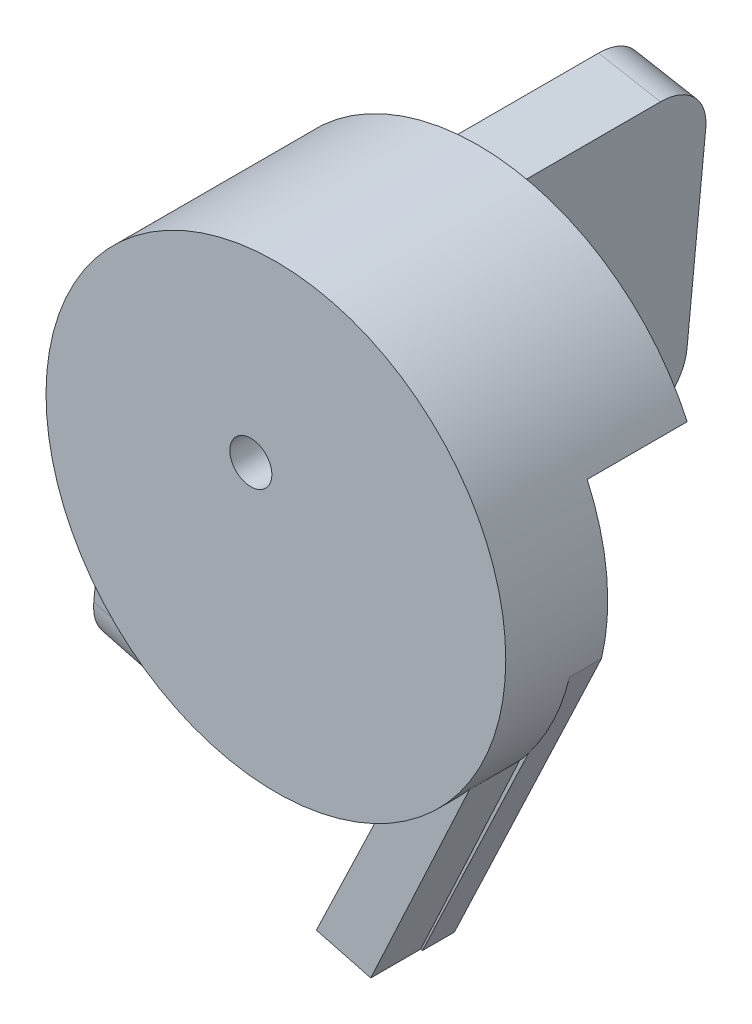
from build123d import *

# Parameters (mm, degrees)
BOSS_EXTRUDE3_DEPTH = 13.2
BOSS_EXTRUDE4_DEPTH = 40
SKETCH3_R           = 23
BOSS_EXTRUDE5_DEPTH = 7
SKETCH4_R           = 2.101716342
CUT_EXTRUDE1_DEPTH  = 10
SKETCH6_W           = 25.714942096
SKETCH6_H           = 53.927163671
CUT_EXTRUDE2_DEPTH  = 10
BOSS_EXTRUDE6_DEPTH = 5
SKETCH11_W          = 0.356169872
SKETCH11_H          = 3.96875
SKETCH11_W_2        = 1.526442308
SKETCH11_H_2        = 0.407051282
CUT_EXTRUDE5_DEPTH  = 5
FILLET5_R           = 5
FILLET6_R           = 5
FILLET7_R           = 5
SKETCH12_R          = 1.4
CUT_EXTRUDE6_DEPTH  = 4
SKETCH13_R          = 1.4
CUT_EXTRUDE7_DEPTH  = 4


with BuildPart() as part:
    # Sketch1 → Boss-Extrude3 (new body)
    with BuildSketch(Plane.XY):
        with BuildLine():
            ThreePointArc((-16.733879942, 0.734685024), (4.365374373, 16.171147349), (14.830379862, -7.786034495))
            Line((14.830379862, -7.786034495), (1.98558973, -34.897127547))
            Line((1.98558973, -34.897127547), (7.660402975, -36.381590217))
            Line((7.660402975, -36.381590217), (22.375667903, -5.322545058))
            ThreePointArc((22.375667903, -5.322545058), (3.672252171, 22.704945805), (-22.912677541, 2.002300652))
            Line((-22.912677541, 2.002300652), (-25.690659105, -27.657354808))
            Line((-25.690659105, -27.657354808), (-19.543738844, -29.265314976))
            Line((-19.543738844, -29.265314976), (-16.733879942, 0.734685024))
        make_face()
    extrude(amount=BOSS_EXTRUDE3_DEPTH)

    # Sketch2 → Boss-Extrude4 (add)
    with BuildSketch(Plane(origin=(0, 0, 0), x_dir=(-1, 0, 0), z_dir=(0, 0, -1))):
        Polygon((22.912677541, 2.002300652), (16.720636216, 0.876084213), (19.543738844, -29.265314976), (25.690659105, -27.657354808), align=None)
    extrude(amount=BOSS_EXTRUDE4_DEPTH)

    # Sketch3 → Boss-Extrude5 (add)
    with BuildSketch(Plane.XY.offset(13.2)):
        Circle(SKETCH3_R)
    extrude(amount=BOSS_EXTRUDE5_DEPTH)

    # Sketch4 → Cut-Extrude1 (cut)
    with BuildSketch(Plane.XY.offset(20.2)):
        with Locations((-2.506003926, 4.326655096)):
            Circle(SKETCH4_R)
    extrude(amount=-CUT_EXTRUDE1_DEPTH, mode=Mode.SUBTRACT)

    # Sketch6 → Cut-Extrude2 (cut)
    with BuildSketch(Plane(origin=(0, 0, 0), x_dir=(-1, 0, 0), z_dir=(0, 0, -1))):
        with Locations((-13.331770184, -17.473361846)):
            Rectangle(SKETCH6_W, SKETCH6_H)
    extrude(amount=-CUT_EXTRUDE2_DEPTH, mode=Mode.SUBTRACT)

    # Sketch7 → Boss-Extrude6 (add)
    with BuildSketch(Plane.XY.offset(13.2)):
        with BuildLine():
            Line((8.554145329, -21.350095964), (2.050563603, -34.914123928))
            Line((2.050563603, -34.914123928), (7.494260499, -36.33812935))
            Line((7.494260499, -36.33812935), (17.377955101, -15.066740739))
            ThreePointArc((17.377955101, -15.066740739), (13.34123669, -18.735298332), (8.554145329, -21.350095964))
        make_face()
    extrude(amount=BOSS_EXTRUDE6_DEPTH)

    # Sketch11 → Cut-Extrude5 (cut)
    with BuildSketch(Plane(origin=(-22.899331118, 2.144796313, 0), x_dir=(0, 0, 1), z_dir=(-0.995642368, 0.093253819, 0))):
        with BuildLine():
            Line((-27.490761449, -14.449425234), (-27.796049911, -14.738813255))
            add(Edge.make_bspline(
                [(-27.796049911, -14.738813255), (-27.85129365, -14.68684433), (-27.96046381, -14.584145708), (-28.138445513, -14.450896634), (-28.324141777, -14.336748466), (-28.516583626, -14.243872645), (-28.711005379, -14.169767282), (-28.904826402, -14.117007695), (-29.096058582, -14.083361157), (-29.223248195, -14.079337559), (-29.285921205, -14.077354922)],
                knots=[0, 0, 0, 0, 0.000227393, 0.000449364, 0.000665615, 0.000880379, 0.001089464, 0.001288886, 0.001482323, 0.001670233, 0.001670233, 0.001670233, 0.001670233], degree=3))
            add(Edge.make_bspline(
                [(-29.285921205, -14.077354922), (-29.324378052, -14.077823921), (-29.401192007, -14.078760704), (-29.515290104, -14.090717091), (-29.628191559, -14.107912963), (-29.739683243, -14.132793485), (-29.849981933, -14.164326972), (-29.958704016, -14.203771203), (-30.066052303, -14.249757953), (-30.171015627, -14.302896651), (-30.272774948, -14.36127112), (-30.368883145, -14.42596009), (-30.459952803, -14.494890236), (-30.544272214, -14.569787329), (-30.622326399, -14.649972935), (-30.695973213, -14.733955434), (-30.762622468, -14.824029298), (-30.822824057, -14.918537284), (-30.87652875, -15.015819499), (-30.923936776, -15.114939585), (-30.963734367, -15.215568777), (-30.995222946, -15.317833348), (-31.021201991, -15.420942141), (-31.039478206, -15.525609101), (-31.0497819, -15.631946298), (-31.051564187, -15.703153904), (-31.052460167, -15.738950975)],
                knots=[0, 0, 0, 0, 0.000115322, 0.000230345, 0.000343799, 0.000457798, 0.000572791, 0.000687718, 0.000804532, 0.000922929, 0.001040474, 0.001156236, 0.001270247, 0.001382882, 0.001494196, 0.001605783, 0.001717723, 0.001829979, 0.001941716, 0.002050889, 0.0021594, 0.002266016, 0.002371682, 0.002478206, 0.002584448, 0.002691849, 0.002691849, 0.002691849, 0.002691849], degree=3))
            add(Edge.make_bspline(
                [(-31.052460167, -15.738950975), (-31.051603236, -15.775543777), (-31.049891715, -15.848629457), (-31.038937603, -15.957706665), (-31.018608259, -16.065163862), (-30.991430589, -16.171354156), (-30.957434486, -16.27645941), (-30.915056552, -16.380023953), (-30.864862523, -16.48204395), (-30.806763932, -16.581600176), (-30.743052791, -16.678577176), (-30.671679833, -16.769925919), (-30.595864707, -16.856862836), (-30.512845374, -16.937457676), (-30.425283929, -17.013866201), (-30.330564295, -17.083983266), (-30.230549005, -17.149159466), (-30.12508547, -17.208573376), (-30.015318029, -17.261650912), (-29.902767961, -17.308849437), (-29.787075706, -17.347719757), (-29.668849263, -17.379399571), (-29.548229571, -17.405366873), (-29.424604366, -17.422072453), (-29.298882634, -17.434195092), (-29.214134364, -17.43508145), (-29.171438032, -17.435527998)],
                knots=[0, 0, 0, 0, 0.000109785, 0.00021927, 0.000328423, 0.000437561, 0.000547932, 0.000659544, 0.000772965, 0.000888736, 0.00100516, 0.001120769, 0.001236245, 0.001350932, 0.001467605, 0.001584633, 0.001704151, 0.001825542, 0.001947502, 0.002069752, 0.002191435, 0.00231332, 0.002436812, 0.002561276, 0.002687381, 0.002815419, 0.002815419, 0.002815419, 0.002815419], degree=3))
            add(Edge.make_bspline(
                [(-29.171438032, -17.435527998), (-29.119982227, -17.434452381), (-29.018940395, -17.43234023), (-28.870411125, -17.415897938), (-28.727759429, -17.390218092), (-28.591386145, -17.352610334), (-28.461132881, -17.304640988), (-28.336522135, -17.246815862), (-28.218534986, -17.176917036), (-28.106816744, -17.098025241), (-28.003904579, -17.010128957), (-27.911087849, -16.91528212), (-27.829846982, -16.813945116), (-27.758971117, -16.706714803), (-27.700337197, -16.592703609), (-27.652210099, -16.472470257), (-27.61531967, -16.345960667), (-27.600176082, -16.258544263), (-27.59252427, -16.214374152)],
                knots=[0, 0, 0, 0, 0.000154335, 0.000303061, 0.000447768, 0.000588759, 0.000726848, 0.000863779, 0.001000266, 0.001137694, 0.001273596, 0.001405716, 0.001535217, 0.001662669, 0.001790677, 0.001919117, 0.002050709, 0.002185113, 0.002185113, 0.002185113, 0.002185113], degree=3))
            Line((-27.59252427, -16.214374152), (-28.915440936, -16.214374152))
            Line((-28.915440936, -16.214374152), (-28.915440936, -15.80732287))
            Line((-28.915440936, -15.80732287), (-27.236354398, -15.80732287))
            add(Edge.make_bspline(
                [(-27.236354398, -15.80732287), (-27.238288708, -15.883191183), (-27.242074503, -16.031679177), (-27.26862988, -16.248225824), (-27.311511104, -16.45275444), (-27.370090207, -16.645480423), (-27.445921999, -16.826130658), (-27.538192633, -16.99488856), (-27.648378878, -17.150663903), (-27.772555896, -17.294728398), (-27.91191567, -17.42323563), (-28.062692587, -17.536181649), (-28.225135757, -17.631321222), (-28.399091521, -17.708723937), (-28.583990405, -17.769132842), (-28.780260264, -17.811963112), (-28.987634936, -17.837623874), (-29.129757775, -17.840902492), (-29.202443891, -17.84257928)],
                knots=[0, 0, 0, 0, 0.000227576, 0.000445408, 0.000653412, 0.000853841, 0.001048745, 0.001240174, 0.001429639, 0.00162013, 0.00180972, 0.001997187, 0.002184263, 0.002373234, 0.002567323, 0.002766779, 0.002975044, 0.003193056, 0.003193056, 0.003193056, 0.003193056], degree=3))
            add(Edge.make_bspline(
                [(-29.202443891, -17.84257928), (-29.247245562, -17.841933938), (-29.335608898, -17.840661114), (-29.466113789, -17.831615371), (-29.593020377, -17.817690075), (-29.716310173, -17.79666123), (-29.836436686, -17.770904434), (-29.952799965, -17.737922173), (-30.06584328, -17.699744273), (-30.175741353, -17.656319714), (-30.281496687, -17.606005425), (-30.383580327, -17.550091816), (-30.482556559, -17.488867202), (-30.577751183, -17.421272761), (-30.6696602, -17.347814078), (-30.75769098, -17.26834392), (-30.842336342, -17.18310524), (-30.895359368, -17.122577255), (-30.922076553, -17.092078479)],
                knots=[0, 0, 0, 0, 0.000134396, 0.000265073, 0.000392289, 0.000517239, 0.000640121, 0.000760684, 0.000879852, 0.000997958, 0.001114959, 0.001230945, 0.001346988, 0.001463899, 0.001580984, 0.001699762, 0.001819504, 0.001941119, 0.001941119, 0.001941119, 0.001941119], degree=3))
            add(Edge.make_bspline(
                [(-30.922076553, -17.092078479), (-30.960840958, -17.043693007), (-31.037726319, -16.94772521), (-31.136693514, -16.793964559), (-31.221059391, -16.634758878), (-31.289512189, -16.469664969), (-31.342963412, -16.298837255), (-31.381297288, -16.122494023), (-31.403757339, -15.940408192), (-31.406993047, -15.817189543), (-31.408630039, -15.754851416)],
                knots=[0, 0, 0, 0, 0.000185896, 0.000368706, 0.000547588, 0.000725795, 0.000904073, 0.00108387, 0.001266496, 0.001453496, 0.001453496, 0.001453496, 0.001453496], degree=3))
            add(Edge.make_bspline(
                [(-31.408630039, -15.754851416), (-31.408026519, -15.708171826), (-31.406827149, -15.615405915), (-31.39228393, -15.477682004), (-31.371418036, -15.34240354), (-31.340748608, -15.209681106), (-31.30208588, -15.07942606), (-31.253833266, -14.951577922), (-31.197652893, -14.826061246), (-31.132355053, -14.703739985), (-31.059687854, -14.586237303), (-30.980822872, -14.474026222), (-30.894640218, -14.369150229), (-30.802547303, -14.270281128), (-30.703445358, -14.178661007), (-30.598262797, -14.093441613), (-30.48691856, -14.014508635), (-30.369062356, -13.94310534), (-30.246453286, -13.878966235), (-30.119385248, -13.822735611), (-29.987897033, -13.776263458), (-29.852973733, -13.736832476), (-29.713594067, -13.707673343), (-29.570769485, -13.686526998), (-29.423755518, -13.67205739), (-29.324382521, -13.670893689), (-29.273995874, -13.670303639)],
                knots=[0, 0, 0, 0, 0.00013998, 0.000278182, 0.000415029, 0.000550417, 0.000686496, 0.000822349, 0.000960062, 0.00109877, 0.00123799, 0.00137431, 0.001509903, 0.001644898, 0.00177935, 0.001914441, 0.002050761, 0.002188472, 0.002327512, 0.002465629, 0.002604942, 0.002745598, 0.002887025, 0.003031729, 0.003178637, 0.003329743, 0.003329743, 0.003329743, 0.003329743], degree=3))
            add(Edge.make_bspline(
                [(-29.273995874, -13.670303639), (-29.232904294, -13.670960742), (-29.15142452, -13.672263698), (-29.030178377, -13.68129504), (-28.910806298, -13.69560962), (-28.793131285, -13.715143565), (-28.677554066, -13.741749714), (-28.563745391, -13.773588483), (-28.451540283, -13.810658675), (-28.341290393, -13.854869242), (-28.232254412, -13.905049692), (-28.123826075, -13.961534555), (-28.016375858, -14.025289694), (-27.909717424, -14.096504417), (-27.803178192, -14.173955614), (-27.698443285, -14.259858441), (-27.59298459, -14.350825316), (-27.525173604, -14.416232792), (-27.490761449, -14.449425234)],
                knots=[0, 0, 0, 0, 0.000123269, 0.000244429, 0.000364538, 0.000483868, 0.000602094, 0.000720146, 0.000838308, 0.000956413, 0.001076296, 0.001198266, 0.001323024, 0.001450914, 0.001582897, 0.001717987, 0.001857171, 0.002000577, 0.002000577, 0.002000577, 0.002000577], degree=3))
        make_face()
        with Locations((-26.244166898, -15.75644146)):
            Rectangle(SKETCH11_W, SKETCH11_H)
        Polygon((-23.420248629, -13.77206646), (-21.588517859, -17.74081646), (-21.975693591, -17.74081646), (-22.562419853, -16.468781204), (-24.361554718, -16.468781204), (-24.964976443, -17.74081646), (-25.353742218, -17.74081646), (-23.471130039, -13.77206646), align=None)
        Polygon((-23.449664444, -14.5456229), (-24.168364364, -16.061729922), (-22.750045053, -16.061729922), align=None, mode=Mode.SUBTRACT)
        with BuildLine():
            Line((-20.876178116, -13.77206646), (-20.520008244, -13.77206646))
            Line((-20.520008244, -13.77206646), (-20.520008244, -16.149977367))
            add(Edge.make_bspline(
                [(-20.520008244, -16.149977367), (-20.520061248, -16.183633202), (-20.520161833, -16.247500947), (-20.519489965, -16.338406074), (-20.517608359, -16.419223951), (-20.516422089, -16.490266104), (-20.513783059, -16.551206541), (-20.51163081, -16.60237542), (-20.508863393, -16.643530453), (-20.505537447, -16.667548111), (-20.504107803, -16.677871999)],
                knots=[0, 0, 0, 0, 0.000100968, 0.000191604, 0.000272712, 0.000343486, 0.00040475, 0.000455687, 0.00049715, 0.00052841, 0.00052841, 0.00052841, 0.00052841], degree=3))
            add(Edge.make_bspline(
                [(-20.504107803, -16.677871999), (-20.498236935, -16.715117882), (-20.486826, -16.787510977), (-20.45774484, -16.890594475), (-20.417130352, -16.983498897), (-20.369002973, -17.069123307), (-20.305579387, -17.145084456), (-20.229602164, -17.215061063), (-20.137552373, -17.276261234), (-20.035203293, -17.332221529), (-19.924888783, -17.3771989), (-19.812163508, -17.411209232), (-19.698721915, -17.431936199), (-19.622775728, -17.434336203), (-19.58506233, -17.435527998)],
                knots=[0, 0, 0, 0, 0.000113064, 0.000219757, 0.000320182, 0.000416724, 0.000513328, 0.000615741, 0.000725557, 0.000844018, 0.00096523, 0.001082195, 0.001196825, 0.001309897, 0.001309897, 0.001309897, 0.001309897], degree=3))
            add(Edge.make_bspline(
                [(-19.58506233, -17.435527998), (-19.552684428, -17.434310329), (-19.488115631, -17.431882023), (-19.392177981, -17.416844507), (-19.298742144, -17.389742973), (-19.20734673, -17.35477289), (-19.12167731, -17.308568032), (-19.041686086, -17.255193062), (-18.970289482, -17.192587872), (-18.905136217, -17.123304446), (-18.848400173, -17.045131637), (-18.799220397, -16.959771606), (-18.75893653, -16.865939757), (-18.739043426, -16.799996796), (-18.728823599, -16.766119445)],
                knots=[0, 0, 0, 0, 9.7152e-05, 0.000193743, 0.00029039, 0.000388568, 0.00048673, 0.000581767, 0.000676452, 0.000770956, 0.000866524, 0.000965529, 0.001065954, 0.001172053, 0.001172053, 0.001172053, 0.001172053], degree=3))
            add(Edge.make_bspline(
                [(-18.728823599, -16.766119445), (-18.725421671, -16.752117043), (-18.717840805, -16.720914051), (-18.710757102, -16.66816223), (-18.703379167, -16.605921612), (-18.698259967, -16.533745003), (-18.693269297, -16.451874257), (-18.690283581, -16.359882876), (-18.688903552, -16.258104893), (-18.688492299, -16.187078826), (-18.688277475, -16.149977367)],
                knots=[0, 0, 0, 0, 4.3203e-05, 9.6273e-05, 0.000159486, 0.000231254, 0.00031328, 0.000405558, 0.000507333, 0.000618639, 0.000618639, 0.000618639, 0.000618639], degree=3))
            Line((-18.688277475, -16.149977367), (-18.688277475, -13.77206646))
            Line((-18.688277475, -13.77206646), (-18.332107603, -13.77206646))
            Line((-18.332107603, -13.77206646), (-18.332107603, -16.169057896))
            add(Edge.make_bspline(
                [(-18.332107603, -16.169057896), (-18.332395757, -16.212258737), (-18.332958108, -16.296567803), (-18.337834655, -16.420110862), (-18.345610003, -16.537305761), (-18.356595602, -16.648168252), (-18.371151847, -16.752301629), (-18.387338927, -16.850618643), (-18.407953219, -16.942413555), (-18.43203038, -17.0284021), (-18.459554849, -17.110255316), (-18.495206866, -17.187939191), (-18.535375718, -17.263815341), (-18.583017334, -17.336736143), (-18.636551669, -17.407024466), (-18.697162057, -17.474254043), (-18.762843918, -17.539499211), (-18.834689133, -17.601086349), (-18.91151339, -17.65756583), (-18.993088163, -17.707229374), (-19.078786822, -17.749211512), (-19.168386599, -17.783769034), (-19.26192573, -17.809752552), (-19.359406576, -17.829114559), (-19.461051018, -17.840116272), (-19.530180584, -17.841751317), (-19.56518678, -17.84257928)],
                knots=[0, 0, 0, 0, 0.000129598, 0.000252919, 0.000370851, 0.000481918, 0.000587044, 0.000686247, 0.000780758, 0.000869105, 0.000954087, 0.001039492, 0.001125214, 0.001211437, 0.001300483, 0.00139001, 0.001482769, 0.001578056, 0.001673624, 0.001768522, 0.001864166, 0.001959545, 0.002056192, 0.002155044, 0.002257413, 0.002362431, 0.002362431, 0.002362431, 0.002362431], degree=3))
            add(Edge.make_bspline(
                [(-19.56518678, -17.84257928), (-19.603365137, -17.841689413), (-19.678270938, -17.839943495), (-19.788645353, -17.829939127), (-19.894456987, -17.811095055), (-19.996823383, -17.78710119), (-20.094350875, -17.754008917), (-20.18834612, -17.715344079), (-20.277199267, -17.667858257), (-20.362351779, -17.615024677), (-20.441528065, -17.555578882), (-20.514209942, -17.490786006), (-20.580517403, -17.421683971), (-20.639332799, -17.347524628), (-20.691630588, -17.268884746), (-20.736681812, -17.185541858), (-20.775363794, -17.097528231), (-20.795328384, -17.036349156), (-20.805421155, -17.005421077)],
                knots=[0, 0, 0, 0, 0.000114552, 0.000224751, 0.000332058, 0.000436763, 0.00053984, 0.000640686, 0.000741328, 0.000841696, 0.000941074, 0.001037929, 0.001133524, 0.001228011, 0.001321503, 0.001416488, 0.001511904, 0.001609455, 0.001609455, 0.001609455, 0.001609455], degree=3))
            add(Edge.make_bspline(
                [(-20.805421155, -17.005421077), (-20.811291682, -16.984293069), (-20.824024987, -16.938465948), (-20.837660816, -16.862621447), (-20.849123792, -16.775292032), (-20.859902416, -16.676471724), (-20.866262574, -16.566083928), (-20.871838598, -16.444176497), (-20.876217398, -16.310602023), (-20.876191576, -16.217558063), (-20.876178116, -16.169057896)],
                knots=[0, 0, 0, 0, 6.5757e-05, 0.000142627, 0.000230889, 0.000330012, 0.000440752, 0.000562517, 0.00069614, 0.000841631, 0.000841631, 0.000841631, 0.000841631], degree=3))
            Line((-20.876178116, -16.169057896), (-20.876178116, -13.77206646))
        make_face()
        with Locations((-16.907428116, -16.214374152)):
            Rectangle(SKETCH11_W_2, SKETCH11_H_2)
        with BuildLine():
            Line((-12.17466194, -17.298784208), (-11.564880039, -18.046104922))
            Line((-11.564880039, -18.046104922), (-12.009297357, -18.046104922))
            Line((-12.009297357, -18.046104922), (-12.449739564, -17.507079982))
            add(Edge.make_bspline(
                [(-12.449739564, -17.507079982), (-12.493914125, -17.533924307), (-12.581449515, -17.587118463), (-12.717936684, -17.655682777), (-12.857138096, -17.71273723), (-12.998745753, -17.759874611), (-13.142553396, -17.79760532), (-13.28929026, -17.823792027), (-13.438424142, -17.838998322), (-13.538620794, -17.841381077), (-13.589006141, -17.84257928)],
                knots=[0, 0, 0, 0, 0.000155029, 0.000307203, 0.000457647, 0.000605978, 0.000754649, 0.000903267, 0.001052702, 0.001203858, 0.001203858, 0.001203858, 0.001203858], degree=3))
            add(Edge.make_bspline(
                [(-13.589006141, -17.84257928), (-13.66119242, -17.840840575), (-13.803233529, -17.837419321), (-14.011842501, -17.807551124), (-14.212075712, -17.761422321), (-14.403534053, -17.694678532), (-14.586426086, -17.609426967), (-14.760666841, -17.504323949), (-14.926344878, -17.380825276), (-15.081014538, -17.239738051), (-15.222444253, -17.086254803), (-15.346539965, -16.922264875), (-15.452054849, -16.750489484), (-15.537369919, -16.570072038), (-15.605078829, -16.3825832), (-15.651220615, -16.186463683), (-15.681087656, -15.982880958), (-15.684528412, -15.844265934), (-15.68627427, -15.773931945)],
                knots=[0, 0, 0, 0, 0.000216456, 0.000425922, 0.000630911, 0.000832053, 0.001033007, 0.001235207, 0.001441436, 0.001651929, 0.001862372, 0.002066694, 0.002267946, 0.002466023, 0.00266443, 0.002864779, 0.00306952, 0.003280416, 0.003280416, 0.003280416, 0.003280416], degree=3))
            add(Edge.make_bspline(
                [(-15.68627427, -15.773931945), (-15.685653112, -15.726725043), (-15.684415161, -15.632642907), (-15.670094605, -15.493297632), (-15.648817807, -15.356246341), (-15.618722602, -15.222058564), (-15.579325468, -15.090184284), (-15.532092373, -14.960883537), (-15.47486319, -14.834489499), (-15.410166988, -14.711260858), (-15.338012165, -14.592265645), (-15.259412278, -14.479197478), (-15.174173965, -14.373170651), (-15.082357568, -14.274233676), (-14.984329773, -14.182167851), (-14.88093354, -14.095457129), (-14.769964255, -14.01732724), (-14.65435074, -13.944669577), (-14.533444649, -13.880777223), (-14.409610901, -13.823659501), (-14.281923153, -13.777315667), (-14.152038164, -13.737825106), (-14.019167936, -13.707676316), (-13.883416023, -13.686555491), (-13.744877926, -13.672096806), (-13.651320155, -13.670905011), (-13.604111559, -13.670303639)],
                knots=[0, 0, 0, 0, 0.00014157, 0.000282145, 0.000419778, 0.000557491, 0.000694332, 0.000832421, 0.000970134, 0.001110248, 0.001249731, 0.001387352, 0.001523061, 0.001657514, 0.001791929, 0.001926295, 0.002061967, 0.002198741, 0.002335672, 0.002471936, 0.002607512, 0.00274283, 0.002878992, 0.00301584, 0.003154833, 0.003296402, 0.003296402, 0.003296402, 0.003296402], degree=3))
            add(Edge.make_bspline(
                [(-13.604111559, -13.670303639), (-13.53192501, -13.672033616), (-13.390146009, -13.675431399), (-13.18205383, -13.7053041), (-12.982410497, -13.751618009), (-12.791358132, -13.818021656), (-12.609067075, -13.903487915), (-12.435613909, -14.008569748), (-12.270729715, -14.132076602), (-12.116868253, -14.273173274), (-11.975771633, -14.427034728), (-11.852264585, -14.591918901), (-11.74718346, -14.765372159), (-11.661714579, -14.94766287), (-11.595320801, -15.138716539), (-11.548909755, -15.338610937), (-11.519179691, -15.546989497), (-11.515744445, -15.689027096), (-11.513998629, -15.761211592)],
                knots=[0, 0, 0, 0, 0.000216456, 0.000425134, 0.00062935, 0.000830492, 0.001030725, 0.001232244, 0.001437837, 0.001647742, 0.001857648, 0.00206324, 0.002264759, 0.002464993, 0.002666135, 0.00287035, 0.003079816, 0.003296272, 0.003296272, 0.003296272, 0.003296272], degree=3))
            add(Edge.make_bspline(
                [(-11.513998629, -15.761211592), (-11.515906597, -15.836320034), (-11.51965851, -15.984016533), (-11.551587929, -16.200597713), (-11.602924829, -16.407483759), (-11.675726754, -16.60453912), (-11.76984319, -16.791727977), (-11.883455877, -16.970922238), (-12.017932725, -17.142109198), (-12.12186868, -17.246009207), (-12.17466194, -17.298784208)],
                knots=[0, 0, 0, 0, 0.000225228, 0.000442899, 0.000655195, 0.000863723, 0.001071717, 0.00128257, 0.00149936, 0.001723147, 0.001723147, 0.001723147, 0.001723147], degree=3))
        make_face()
        with BuildLine():
            add(Edge.make_bspline(
                [(-12.413963572, -17.005421077), (-12.370660336, -16.961443956), (-12.28548095, -16.874939009), (-12.174962372, -16.733075472), (-12.079905308, -16.5856112), (-12.003801779, -16.430584568), (-11.943251046, -16.269937831), (-11.90141714, -16.102398087), (-11.875223298, -15.928728057), (-11.871865821, -15.81059611), (-11.8701685, -15.750876306)],
                knots=[0, 0, 0, 0, 0.000185022, 0.000363946, 0.000538396, 0.000710482, 0.000881043, 0.001052462, 0.001227634, 0.001406728, 0.001406728, 0.001406728, 0.001406728], degree=3))
            add(Edge.make_bspline(
                [(-11.8701685, -15.750876306), (-11.870611985, -15.712417494), (-11.871488676, -15.6363912), (-11.883543158, -15.523885622), (-11.900596665, -15.413864877), (-11.925284916, -15.30652554), (-11.957077316, -15.202085087), (-11.996343724, -15.100685296), (-12.042319095, -15.001999045), (-12.095916332, -14.906639367), (-12.155002751, -14.814744474), (-12.220773184, -14.727438199), (-12.292301874, -14.645170717), (-12.368807404, -14.566586298), (-12.451764799, -14.493304857), (-12.540876543, -14.425357806), (-12.635044577, -14.361100845), (-12.734734885, -14.303100644), (-12.837465718, -14.24977851), (-12.942635957, -14.203604841), (-13.049362522, -14.164497398), (-13.15748014, -14.132786284), (-13.266848906, -14.107825599), (-13.377660566, -14.090791174), (-13.489628561, -14.078749105), (-13.56485845, -14.077820046), (-13.602521515, -14.077354922)],
                knots=[0, 0, 0, 0, 0.000115322, 0.000227971, 0.00033907, 0.000449191, 0.000558086, 0.000666308, 0.000775142, 0.000884408, 0.000994227, 0.001102668, 0.001212012, 0.001321078, 0.001431469, 0.001543733, 0.001657073, 0.001773244, 0.001889516, 0.002004143, 0.002117575, 0.002230278, 0.002341949, 0.002453833, 0.002566482, 0.00267942, 0.00267942, 0.00267942, 0.00267942], degree=3))
            add(Edge.make_bspline(
                [(-13.602521515, -14.077354922), (-13.640448888, -14.077823291), (-13.716206211, -14.078758827), (-13.828714769, -14.090724571), (-13.939780742, -14.107844351), (-14.04891564, -14.132680979), (-14.156505948, -14.164453762), (-14.262217715, -14.203797631), (-14.366970265, -14.24883083), (-14.468589884, -14.302118917), (-14.566898775, -14.360617864), (-14.660396751, -14.4242359), (-14.747802489, -14.493607745), (-14.829945116, -14.567616518), (-14.906619467, -14.646833253), (-14.97818756, -14.730731003), (-15.043392535, -14.820283239), (-15.103132558, -14.913887729), (-15.155933624, -15.011646174), (-15.203553486, -15.111794779), (-15.242231392, -15.215437669), (-15.273985132, -15.321745289), (-15.299932744, -15.430453349), (-15.316656987, -15.542192897), (-15.328801891, -15.656266385), (-15.329666886, -15.733352159), (-15.330104398, -15.772341901)],
                knots=[0, 0, 0, 0, 0.000113733, 0.000227173, 0.000339057, 0.000450728, 0.000562668, 0.000675354, 0.000788934, 0.0009045, 0.001019303, 0.001131986, 0.001243484, 0.001353812, 0.001463447, 0.001573998, 0.001684355, 0.001795513, 0.001906867, 0.002017478, 0.002127929, 0.002238345, 0.002350195, 0.002462864, 0.002577096, 0.002694007, 0.002694007, 0.002694007, 0.002694007], degree=3))
            add(Edge.make_bspline(
                [(-15.330104398, -15.772341901), (-15.328614918, -15.829665291), (-15.325684652, -15.942438134), (-15.301393471, -16.108008131), (-15.260666258, -16.266516026), (-15.203687196, -16.418188584), (-15.132157799, -16.563900018), (-15.043205585, -16.702222842), (-14.937210049, -16.832630204), (-14.818181049, -16.956017825), (-14.687247372, -17.067802068), (-14.548444975, -17.166184407), (-14.40295892, -17.249653105), (-14.250332357, -17.317022083), (-14.091703427, -17.371121652), (-13.925819918, -17.407748141), (-13.753766215, -17.432025162), (-13.636527743, -17.434349447), (-13.57708081, -17.435527998)],
                knots=[0, 0, 0, 0, 0.000171909, 0.000338198, 0.00050075, 0.000662006, 0.000823425, 0.00098684, 0.001154211, 0.001326819, 0.00150049, 0.001669897, 0.001836549, 0.002002756, 0.002169692, 0.00233845, 0.002511715, 0.002689944, 0.002689944, 0.002689944, 0.002689944], degree=3))
            add(Edge.make_bspline(
                [(-13.57708081, -17.435527998), (-13.536238513, -17.435083078), (-13.455455333, -17.434203057), (-13.336331595, -17.422205391), (-13.220122938, -17.40531843), (-13.107905482, -17.379635015), (-12.998706129, -17.347704882), (-12.893174867, -17.308864757), (-12.790751892, -17.262819463), (-12.725626894, -17.226392217), (-12.693016307, -17.208151696)],
                knots=[0, 0, 0, 0, 0.000122475, 0.000242246, 0.000358844, 0.000474568, 0.000587271, 0.000699956, 0.000811679, 0.000923732, 0.000923732, 0.000923732, 0.000923732], degree=3))
            Line((-12.693016307, -17.208151696), (-13.586621074, -16.112611332))
            Line((-13.586621074, -16.112611332), (-13.142203757, -16.112611332))
            Line((-13.142203757, -16.112611332), (-12.413963572, -17.005421077))
        make_face(mode=Mode.SUBTRACT)
        with BuildLine():
            Line((-10.699896064, -13.77206646), (-10.343726193, -13.77206646))
            Line((-10.343726193, -13.77206646), (-10.343726193, -16.149977367))
            add(Edge.make_bspline(
                [(-10.343726193, -16.149977367), (-10.343779197, -16.183633202), (-10.343879782, -16.247500947), (-10.343207913, -16.338406074), (-10.341326308, -16.419223951), (-10.340140038, -16.490266104), (-10.337501008, -16.551206541), (-10.335348758, -16.60237542), (-10.332581341, -16.643530453), (-10.329255396, -16.667548111), (-10.327825752, -16.677871999)],
                knots=[0, 0, 0, 0, 0.000100968, 0.000191604, 0.000272712, 0.000343486, 0.00040475, 0.000455687, 0.00049715, 0.00052841, 0.00052841, 0.00052841, 0.00052841], degree=3))
            add(Edge.make_bspline(
                [(-10.327825752, -16.677871999), (-10.321954883, -16.715117882), (-10.310543949, -16.787510977), (-10.281462788, -16.890594475), (-10.240848301, -16.983498897), (-10.192720922, -17.069123307), (-10.129297336, -17.145084456), (-10.053320113, -17.215061063), (-9.961270322, -17.276261234), (-9.858921242, -17.332221529), (-9.748606732, -17.3771989), (-9.635881456, -17.411209232), (-9.522439864, -17.431936199), (-9.446493677, -17.434336203), (-9.408780279, -17.435527998)],
                knots=[0, 0, 0, 0, 0.000113064, 0.000219757, 0.000320182, 0.000416724, 0.000513328, 0.000615741, 0.000725557, 0.000844018, 0.00096523, 0.001082195, 0.001196825, 0.001309897, 0.001309897, 0.001309897, 0.001309897], degree=3))
            add(Edge.make_bspline(
                [(-9.408780279, -17.435527998), (-9.376402377, -17.434310329), (-9.311833579, -17.431882023), (-9.21589593, -17.416844507), (-9.122460093, -17.389742973), (-9.031064679, -17.35477289), (-8.945395259, -17.308568032), (-8.865404035, -17.255193062), (-8.794007431, -17.192587872), (-8.728854165, -17.123304446), (-8.672118122, -17.045131637), (-8.622938345, -16.959771606), (-8.582654479, -16.865939757), (-8.562761375, -16.799996796), (-8.552541547, -16.766119445)],
                knots=[0, 0, 0, 0, 9.7152e-05, 0.000193743, 0.00029039, 0.000388568, 0.00048673, 0.000581767, 0.000676452, 0.000770956, 0.000866524, 0.000965529, 0.001065954, 0.001172053, 0.001172053, 0.001172053, 0.001172053], degree=3))
            add(Edge.make_bspline(
                [(-8.552541547, -16.766119445), (-8.549139619, -16.752117043), (-8.541558753, -16.720914051), (-8.534475051, -16.66816223), (-8.527097115, -16.605921612), (-8.521977916, -16.533745003), (-8.516987246, -16.451874257), (-8.51400153, -16.359882876), (-8.512621501, -16.258104893), (-8.512210248, -16.187078826), (-8.511995423, -16.149977367)],
                knots=[0, 0, 0, 0, 4.3203e-05, 9.6273e-05, 0.000159486, 0.000231254, 0.00031328, 0.000405558, 0.000507333, 0.000618639, 0.000618639, 0.000618639, 0.000618639], degree=3))
            Line((-8.511995423, -16.149977367), (-8.511995423, -13.77206646))
            Line((-8.511995423, -13.77206646), (-8.155825552, -13.77206646))
            Line((-8.155825552, -13.77206646), (-8.155825552, -16.169057896))
            add(Edge.make_bspline(
                [(-8.155825552, -16.169057896), (-8.156113706, -16.212258737), (-8.156676057, -16.296567803), (-8.161552603, -16.420110862), (-8.169327951, -16.537305761), (-8.180313551, -16.648168252), (-8.194869796, -16.752301629), (-8.211056876, -16.850618643), (-8.231671168, -16.942413555), (-8.255748328, -17.0284021), (-8.283272798, -17.110255316), (-8.318924814, -17.187939191), (-8.359093667, -17.263815341), (-8.406735282, -17.336736143), (-8.460269618, -17.407024466), (-8.520880006, -17.474254043), (-8.586561867, -17.539499211), (-8.658407082, -17.601086349), (-8.735231338, -17.65756583), (-8.816806112, -17.707229374), (-8.90250477, -17.749211512), (-8.992104547, -17.783769034), (-9.085643679, -17.809752552), (-9.183124525, -17.829114559), (-9.284768967, -17.840116272), (-9.353898532, -17.841751317), (-9.388904728, -17.84257928)],
                knots=[0, 0, 0, 0, 0.000129598, 0.000252919, 0.000370851, 0.000481918, 0.000587044, 0.000686247, 0.000780758, 0.000869105, 0.000954087, 0.001039492, 0.001125214, 0.001211437, 0.001300483, 0.00139001, 0.001482769, 0.001578056, 0.001673624, 0.001768522, 0.001864166, 0.001959545, 0.002056192, 0.002155044, 0.002257413, 0.002362431, 0.002362431, 0.002362431, 0.002362431], degree=3))
            add(Edge.make_bspline(
                [(-9.388904728, -17.84257928), (-9.427083086, -17.841689413), (-9.501988886, -17.839943495), (-9.612363302, -17.829939127), (-9.718174935, -17.811095055), (-9.820541332, -17.78710119), (-9.918068824, -17.754008917), (-10.012064069, -17.715344079), (-10.100917216, -17.667858257), (-10.186069728, -17.615024677), (-10.265246014, -17.555578882), (-10.337927891, -17.490786006), (-10.404235351, -17.421683971), (-10.463050748, -17.347524628), (-10.515348537, -17.268884746), (-10.560399761, -17.185541858), (-10.599081743, -17.097528231), (-10.619046332, -17.036349156), (-10.629139103, -17.005421077)],
                knots=[0, 0, 0, 0, 0.000114552, 0.000224751, 0.000332058, 0.000436763, 0.00053984, 0.000640686, 0.000741328, 0.000841696, 0.000941074, 0.001037929, 0.001133524, 0.001228011, 0.001321503, 0.001416488, 0.001511904, 0.001609455, 0.001609455, 0.001609455, 0.001609455], degree=3))
            add(Edge.make_bspline(
                [(-10.629139103, -17.005421077), (-10.635009631, -16.984293069), (-10.647742936, -16.938465948), (-10.661378765, -16.862621447), (-10.672841741, -16.775292032), (-10.683620365, -16.676471724), (-10.689980523, -16.566083928), (-10.695556547, -16.444176497), (-10.699935347, -16.310602023), (-10.699909525, -16.217558063), (-10.699896064, -16.169057896)],
                knots=[0, 0, 0, 0, 6.5757e-05, 0.000142627, 0.000230889, 0.000330012, 0.000440752, 0.000562517, 0.00069614, 0.000841631, 0.000841631, 0.000841631, 0.000841631], degree=3))
            Line((-10.699896064, -16.169057896), (-10.699896064, -13.77206646))
        make_face()
        Polygon((-5.509992218, -13.77206646), (-3.678261449, -17.74081646), (-4.06543718, -17.74081646), (-4.652163442, -16.468781204), (-6.451298308, -16.468781204), (-7.054720033, -17.74081646), (-7.443485808, -17.74081646), (-5.560873629, -13.77206646), align=None)
        Polygon((-5.539408034, -14.5456229), (-6.258107953, -16.061729922), (-4.839788643, -16.061729922), align=None, mode=Mode.SUBTRACT)
        Polygon((-2.965921705, -17.74081646), (-2.965921705, -13.77206646), (-2.891189634, -13.77206646), (-0.269206962, -16.895708036), (-0.269206962, -13.77206646), (0.08696291, -13.77206646), (0.08696291, -17.74081646), (0.005870662, -17.74081646), (-2.609751834, -14.624330082), (-2.609751834, -17.74081646), align=None)
        with BuildLine():
            Line((4.818934064, -14.449425234), (4.513645602, -14.738813255))
            add(Edge.make_bspline(
                [(4.513645602, -14.738813255), (4.458401863, -14.68684433), (4.349231703, -14.584145708), (4.171249999, -14.450896634), (3.985553736, -14.336748466), (3.793111887, -14.243872645), (3.598690134, -14.169767282), (3.404869111, -14.117007695), (3.213636931, -14.083361157), (3.086447318, -14.079337559), (3.023774308, -14.077354922)],
                knots=[0, 0, 0, 0, 0.000227393, 0.000449364, 0.000665615, 0.000880379, 0.001089464, 0.001288886, 0.001482323, 0.001670233, 0.001670233, 0.001670233, 0.001670233], degree=3))
            add(Edge.make_bspline(
                [(3.023774308, -14.077354922), (2.985317461, -14.077823921), (2.908503506, -14.078760704), (2.794405409, -14.090717091), (2.681503954, -14.107912963), (2.57001227, -14.132793485), (2.459713579, -14.164326972), (2.350991496, -14.203771203), (2.24364321, -14.249757953), (2.138679886, -14.302896651), (2.036920565, -14.36127112), (1.940812368, -14.42596009), (1.84974271, -14.494890236), (1.765423299, -14.569787329), (1.687369114, -14.649972935), (1.6137223, -14.733955434), (1.547073044, -14.824029298), (1.486871456, -14.918537284), (1.433166763, -15.015819499), (1.385758737, -15.114939585), (1.345961146, -15.215568777), (1.314472567, -15.317833348), (1.288493522, -15.420942141), (1.270217306, -15.525609101), (1.259913613, -15.631946298), (1.258131326, -15.703153904), (1.257235346, -15.738950975)],
                knots=[0, 0, 0, 0, 0.000115322, 0.000230345, 0.000343799, 0.000457798, 0.000572791, 0.000687718, 0.000804532, 0.000922929, 0.001040474, 0.001156236, 0.001270247, 0.001382882, 0.001494196, 0.001605783, 0.001717723, 0.001829979, 0.001941716, 0.002050889, 0.0021594, 0.002266016, 0.002371682, 0.002478206, 0.002584448, 0.002691849, 0.002691849, 0.002691849, 0.002691849], degree=3))
            add(Edge.make_bspline(
                [(1.257235346, -15.738950975), (1.258092276, -15.775543777), (1.259803797, -15.848629457), (1.27075791, -15.957706665), (1.291087254, -16.065163862), (1.318264924, -16.171354156), (1.352261027, -16.27645941), (1.394638961, -16.380023953), (1.44483299, -16.48204395), (1.50293158, -16.581600176), (1.566642722, -16.678577176), (1.63801568, -16.769925919), (1.713830806, -16.856862836), (1.796850139, -16.937457676), (1.884411584, -17.013866201), (1.979131218, -17.083983266), (2.079146508, -17.149159466), (2.184610043, -17.208573376), (2.294377484, -17.261650912), (2.406927552, -17.308849437), (2.522619807, -17.347719757), (2.64084625, -17.379399571), (2.761465942, -17.405366873), (2.885091147, -17.422072453), (3.010812879, -17.434195092), (3.095561149, -17.43508145), (3.138257481, -17.435527998)],
                knots=[0, 0, 0, 0, 0.000109785, 0.00021927, 0.000328423, 0.000437561, 0.000547932, 0.000659544, 0.000772965, 0.000888736, 0.00100516, 0.001120769, 0.001236245, 0.001350932, 0.001467605, 0.001584633, 0.001704151, 0.001825542, 0.001947502, 0.002069752, 0.002191435, 0.00231332, 0.002436812, 0.002561276, 0.002687381, 0.002815419, 0.002815419, 0.002815419, 0.002815419], degree=3))
            add(Edge.make_bspline(
                [(3.138257481, -17.435527998), (3.189713286, -17.434452381), (3.290755118, -17.43234023), (3.439284387, -17.415897938), (3.581936084, -17.390218092), (3.718309368, -17.352610334), (3.848562632, -17.304640988), (3.973173378, -17.246815862), (4.091160527, -17.176917036), (4.202878768, -17.098025241), (4.305790934, -17.010128957), (4.398607664, -16.91528212), (4.479848531, -16.813945116), (4.550724396, -16.706714803), (4.609358316, -16.592703609), (4.657485414, -16.472470257), (4.694375843, -16.345960667), (4.709519431, -16.258544263), (4.717171243, -16.214374152)],
                knots=[0, 0, 0, 0, 0.000154335, 0.000303061, 0.000447768, 0.000588759, 0.000726848, 0.000863779, 0.001000266, 0.001137694, 0.001273596, 0.001405716, 0.001535217, 0.001662669, 0.001790677, 0.001919117, 0.002050709, 0.002185113, 0.002185113, 0.002185113, 0.002185113], degree=3))
            Line((4.717171243, -16.214374152), (3.394254577, -16.214374152))
            Line((3.394254577, -16.214374152), (3.394254577, -15.80732287))
            Line((3.394254577, -15.80732287), (5.073341115, -15.80732287))
            add(Edge.make_bspline(
                [(5.073341115, -15.80732287), (5.071406805, -15.883191183), (5.06762101, -16.031679177), (5.041065633, -16.248225824), (4.998184409, -16.45275444), (4.939605305, -16.645480423), (4.863773514, -16.826130658), (4.771502879, -16.99488856), (4.661316635, -17.150663903), (4.537139616, -17.294728398), (4.397779843, -17.42323563), (4.247002926, -17.536181649), (4.084559756, -17.631321222), (3.910603992, -17.708723937), (3.725705108, -17.769132842), (3.529435249, -17.811963112), (3.322060577, -17.837623874), (3.179937738, -17.840902492), (3.107251622, -17.84257928)],
                knots=[0, 0, 0, 0, 0.000227576, 0.000445408, 0.000653412, 0.000853841, 0.001048745, 0.001240174, 0.001429639, 0.00162013, 0.00180972, 0.001997187, 0.002184263, 0.002373234, 0.002567323, 0.002766779, 0.002975044, 0.003193056, 0.003193056, 0.003193056, 0.003193056], degree=3))
            add(Edge.make_bspline(
                [(3.107251622, -17.84257928), (3.06244995, -17.841933938), (2.974086615, -17.840661114), (2.843581724, -17.831615371), (2.716675136, -17.817690075), (2.59338534, -17.79666123), (2.473258827, -17.770904434), (2.356895548, -17.737922173), (2.243852233, -17.699744273), (2.13395416, -17.656319714), (2.028198826, -17.606005425), (1.926115186, -17.550091816), (1.827138954, -17.488867202), (1.73194433, -17.421272761), (1.640035312, -17.347814078), (1.552004533, -17.26834392), (1.467359171, -17.18310524), (1.414336145, -17.122577255), (1.38761896, -17.092078479)],
                knots=[0, 0, 0, 0, 0.000134396, 0.000265073, 0.000392289, 0.000517239, 0.000640121, 0.000760684, 0.000879852, 0.000997958, 0.001114959, 0.001230945, 0.001346988, 0.001463899, 0.001580984, 0.001699762, 0.001819504, 0.001941119, 0.001941119, 0.001941119, 0.001941119], degree=3))
            add(Edge.make_bspline(
                [(1.38761896, -17.092078479), (1.348854555, -17.043693007), (1.271969194, -16.94772521), (1.173001998, -16.793964559), (1.088636122, -16.634758878), (1.020183324, -16.469664969), (0.966732101, -16.298837255), (0.928398225, -16.122494023), (0.905938174, -15.940408192), (0.902702466, -15.817189543), (0.901065474, -15.754851416)],
                knots=[0, 0, 0, 0, 0.000185896, 0.000368706, 0.000547588, 0.000725795, 0.000904073, 0.00108387, 0.001266496, 0.001453496, 0.001453496, 0.001453496, 0.001453496], degree=3))
            add(Edge.make_bspline(
                [(0.901065474, -15.754851416), (0.901668994, -15.708171826), (0.902868364, -15.615405915), (0.917411583, -15.477682004), (0.938277477, -15.34240354), (0.968946905, -15.209681106), (1.007609633, -15.07942606), (1.055862247, -14.951577922), (1.11204262, -14.826061246), (1.177340459, -14.703739985), (1.250007659, -14.586237303), (1.328872641, -14.474026222), (1.415055295, -14.369150229), (1.50714821, -14.270281128), (1.606250155, -14.178661007), (1.711432715, -14.093441613), (1.822776952, -14.014508635), (1.940633156, -13.94310534), (2.063242227, -13.878966235), (2.190310265, -13.822735611), (2.32179848, -13.776263458), (2.45672178, -13.736832476), (2.596101446, -13.707673343), (2.738926028, -13.686526998), (2.885939994, -13.67205739), (2.985312992, -13.670893689), (3.035699639, -13.670303639)],
                knots=[0, 0, 0, 0, 0.00013998, 0.000278182, 0.000415029, 0.000550417, 0.000686496, 0.000822349, 0.000960062, 0.00109877, 0.00123799, 0.00137431, 0.001509903, 0.001644898, 0.00177935, 0.001914441, 0.002050761, 0.002188472, 0.002327512, 0.002465629, 0.002604942, 0.002745598, 0.002887025, 0.003031729, 0.003178637, 0.003329743, 0.003329743, 0.003329743, 0.003329743], degree=3))
            add(Edge.make_bspline(
                [(3.035699639, -13.670303639), (3.076791219, -13.670960742), (3.158270993, -13.672263698), (3.279517136, -13.68129504), (3.398889215, -13.69560962), (3.516564228, -13.715143565), (3.632141447, -13.741749714), (3.745950122, -13.773588483), (3.85815523, -13.810658675), (3.96840512, -13.854869242), (4.077441101, -13.905049692), (4.185869438, -13.961534555), (4.293319655, -14.025289694), (4.399978089, -14.096504417), (4.506517321, -14.173955614), (4.611252228, -14.259858441), (4.716710923, -14.350825316), (4.784521909, -14.416232792), (4.818934064, -14.449425234)],
                knots=[0, 0, 0, 0, 0.000123269, 0.000244429, 0.000364538, 0.000483868, 0.000602094, 0.000720146, 0.000838308, 0.000956413, 0.001076296, 0.001198266, 0.001323024, 0.001450914, 0.001582897, 0.001717987, 0.001857171, 0.002000577, 0.002000577, 0.002000577, 0.002000577], degree=3))
        make_face()
    extrude(amount=-CUT_EXTRUDE5_DEPTH, mode=Mode.SUBTRACT)

    # Fillet5
    fillet5_edges = [part.edges().sort_by_distance(p)[0] for p in [
        (-22.617198974, -28.461334892, -40),
    ]]
    fillet(fillet5_edges, radius=FILLET5_R)

    # Fillet6
    fillet6_edges = [part.edges().sort_by_distance(p)[0] for p in [
        (-19.816656879, 1.439192432, -40),
    ]]
    fillet(fillet6_edges, radius=FILLET6_R)

    # Fillet7
    fillet7_edges = [part.edges().sort_by_distance(p)[0] for p in [
        (-22.617198974, -28.461334892, 13.2),
    ]]
    fillet(fillet7_edges, radius=FILLET7_R)

    # Sketch12 → Cut-Extrude6 (cut)
    with BuildSketch(Plane(origin=(-16.656571158, 1.560087158, 0), x_dir=(0, 0, -1), z_dir=(0.995642368, -0.093253819, 0))):
        with Locations((18.8, -10.686996624)):
            Circle(SKETCH12_R)
    extrude(amount=-CUT_EXTRUDE6_DEPTH, mode=Mode.SUBTRACT)

    # Sketch13 → Cut-Extrude7 (cut)
    with BuildSketch(Plane(origin=(-16.656571158, 1.560087158, 0), x_dir=(0, 0, -1), z_dir=(0.995642368, -0.093253819, 0))):
        with Locations((26.8, -10.686996624)):
            Circle(SKETCH13_R)
    extrude(amount=-CUT_EXTRUDE7_DEPTH, mode=Mode.SUBTRACT)


solid = part.part
